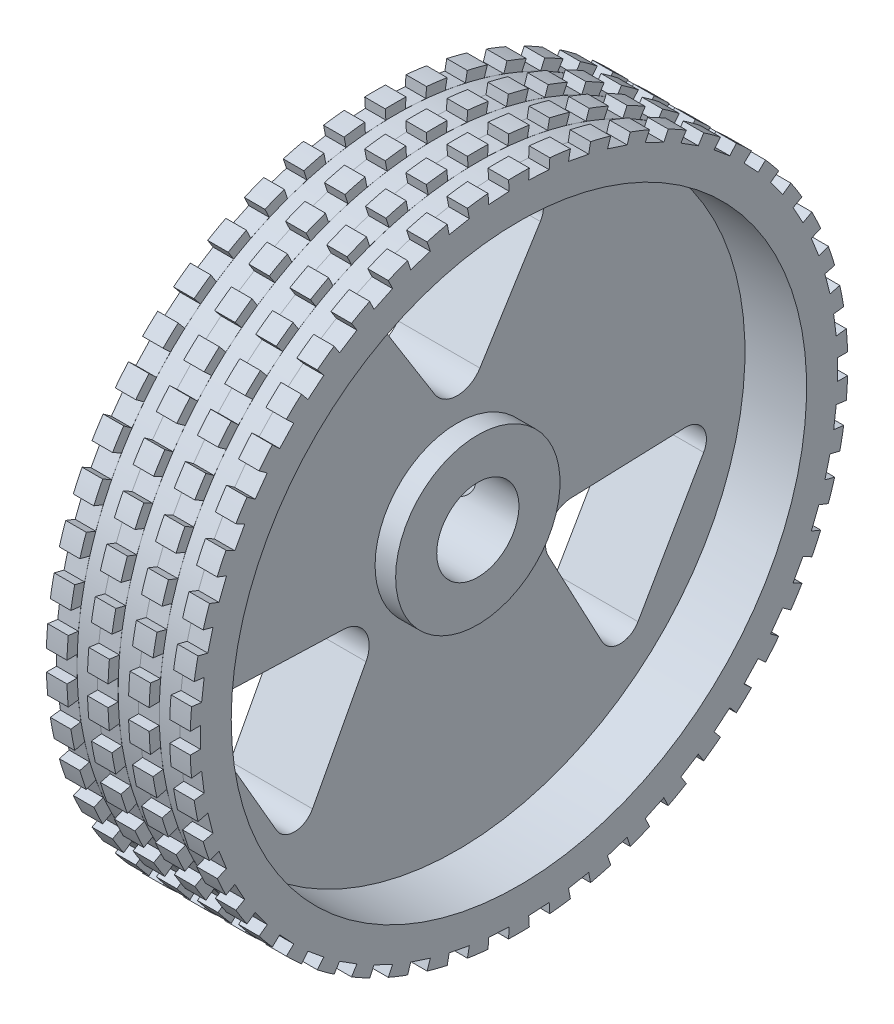
from build123d import *

# Parameters (mm, degrees)
CUT_EXTRUDE1_DEPTH = 23.978250743
FILLET2_R          = 1
FILLET3_R          = 1.3
SKETCH5_W          = 1
SKETCH5_H          = 0.5
LPATTERN1_COUNT    = 3
LPATTERN1_PITCH    = 2
SKETCH9_W          = 0.5
SKETCH9_H          = 1
CUT_EXTRUDE5_DEPTH = 24.6854387
CIRPATTERN1_COUNT  = 50


with BuildPart() as part:
    # Sketch1 → Revolve1 (revolve)
    with BuildSketch(Plane.XY, mode=Mode.PRIVATE) as revolve1_sk:
        Polygon((0, 2), (5, 2), (5, 4), (4, 4), (4, 14), (7, 14), (7, 16), (0, 16), align=None)
    revolve(revolve1_sk.sketch.rotate(Axis((0, 0, 0), (1, 0, 0)), 90), axis=Axis((0, 0, 0), (1, 0, 0)))

    # Sketch3 → Cut-Revolve2 (revolve, cut)
    with BuildSketch(Plane(origin=(0, 0, 0), x_dir=(1, 0, 0), z_dir=(0, 1, 0))):
        Polygon((2, 0), (2, 16), (3.5, 16), (3.5, 11.5), (2.9, 11.5), (2.9, 0), align=None)
    revolve(axis=Axis((2, 0, 0), (0, 0, -1)), mode=Mode.SUBTRACT)

    # Sketch4 → Cut-Extrude1 (cut, through all)
    with BuildSketch(Plane(origin=(4, 0, 0), x_dir=(0, 0, -1), z_dir=(1, 0, 0))):
        Polygon((-5, 12), (5, 12), (0, 4), align=None)
        Polygon((12.892304845, -1.669872981), (7.892304845, -10.330127019), (3.464101615, -2), align=None)
        Polygon((-7.892304845, -10.330127019), (-12.892304845, -1.669872981), (-3.464101615, -2), align=None)
    extrude(amount=-CUT_EXTRUDE1_DEPTH, mode=Mode.SUBTRACT)

    # Fillet2
    fillet2_edges = [part.edges().sort_by_distance(p)[0] for p in [
        (2, 12, 5),
        (2, 12, -5),
        (2, -1.669872981, -12.892304845),
        (2, -10.330127019, -7.892304845),
        (2, -10.330127019, 7.892304845),
        (2, -1.669872981, 12.892304845),
    ]]
    fillet(fillet2_edges, radius=FILLET2_R)

    # Fillet3
    fillet3_edges = [part.edges().sort_by_distance(p)[0] for p in [
        (2, 4, 0),
        (2, -2, -3.464101615),
        (2, -2, 3.464101615),
    ]]
    fillet(fillet3_edges, radius=FILLET3_R)

    # Sketch5 → Cut-Revolve3 (revolve, cut)
    with BuildSketch(Plane(origin=(0, 0, 0), x_dir=(1, 0, 0), z_dir=(0, 1, 0)), mode=Mode.PRIVATE) as cut_revolve3_sk:
        with Locations((5.5, 15.75)):
            Rectangle(SKETCH5_W, SKETCH5_H)
    cut_revolve3 = revolve(cut_revolve3_sk.sketch.rotate(Axis((0, 0, 0), (1, 0, 0)), 180), axis=Axis((0, 0, 0), (1, 0, 0)), mode=Mode.SUBTRACT)

    # LPattern1: Cut-Revolve3 ×3
    with Locations(*[(-i * LPATTERN1_PITCH, 0, 0) for i in range(1, LPATTERN1_COUNT)]):
        add(cut_revolve3, mode=Mode.SUBTRACT)

    # Sketch9 → Cut-Extrude5 (cut, through all)
    with BuildSketch(Plane(origin=(0, 0, 0), x_dir=(0, 0, -1), z_dir=(1, 0, 0))):
        with Locations((15.75, 0)):
            Rectangle(SKETCH9_W, SKETCH9_H)
    cut_extrude5 = extrude(amount=CUT_EXTRUDE5_DEPTH, mode=Mode.SUBTRACT)

    # CirPattern1: Cut-Extrude5 ×50 about axis
    cirpattern1_axis = Axis((0, 0, 0), (1, 0, 0))
    for i in range(1, CIRPATTERN1_COUNT):
        add(cut_extrude5.rotate(cirpattern1_axis, i * 360 / CIRPATTERN1_COUNT), mode=Mode.SUBTRACT)


solid = part.part
